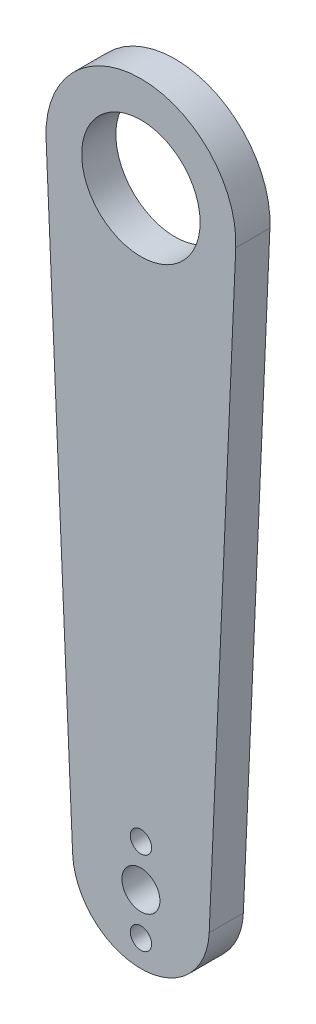
from build123d import *

# Parameters (mm, degrees)
SKETCH1_R           = 7.8
SKETCH1_R_2         = 2.5
SKETCH1_R_3         = 1.4
BOSS_EXTRUDE1_DEPTH = 4.5


with BuildPart() as part:
    # Sketch1 → Boss-Extrude1 (new body)
    with BuildSketch(Plane.XY):
        with BuildLine():
            Line((-8.991382593, -0.39375), (-12.488031379, 79.453125))
            ThreePointArc((-12.488031379, 79.453125), (0, 92.5), (12.488031379, 79.453125))
            Line((12.488031379, 79.453125), (8.991382593, -0.39375))
            ThreePointArc((8.991382593, -0.39375), (0, -9), (-8.991382593, -0.39375))
        make_face()
        with Locations((0, 80)):
            Circle(SKETCH1_R, mode=Mode.SUBTRACT)
        Circle(SKETCH1_R_2, mode=Mode.SUBTRACT)
        with Locations((0, 5.5)):
            Circle(SKETCH1_R_3, mode=Mode.SUBTRACT)
        with Locations((0, -5.5)):
            Circle(SKETCH1_R_3, mode=Mode.SUBTRACT)
    extrude(amount=BOSS_EXTRUDE1_DEPTH)


solid = part.part
